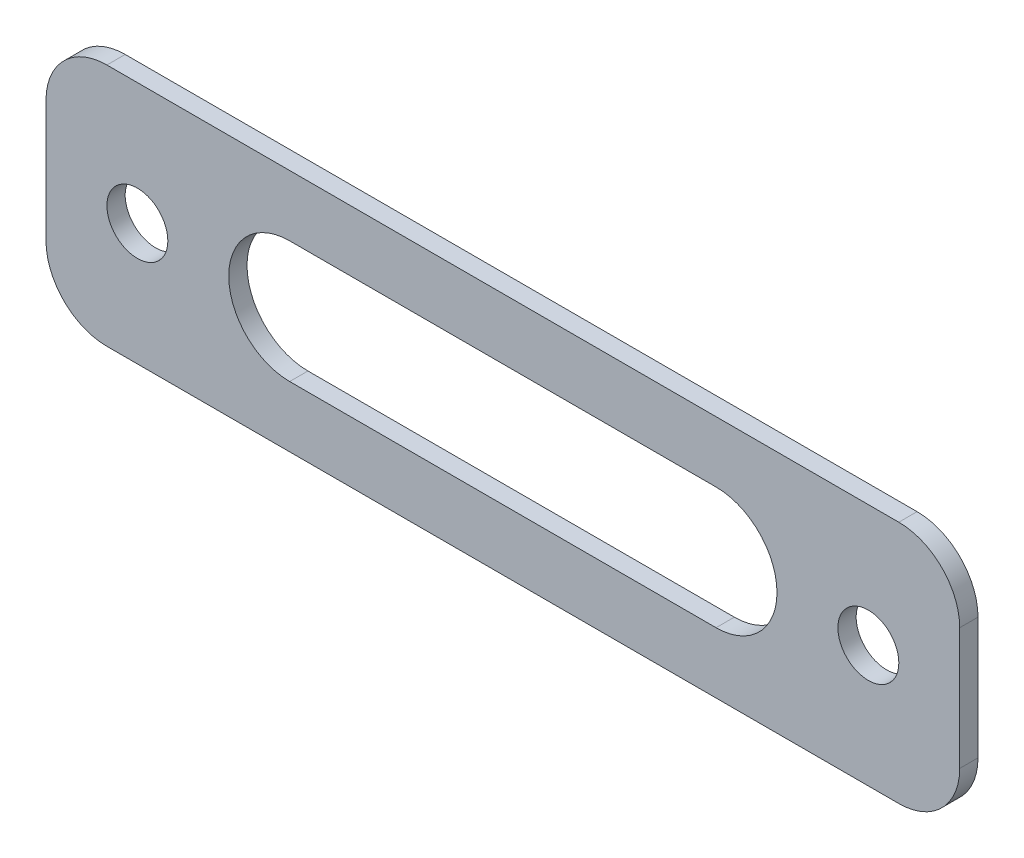
from build123d import *

# Parameters (mm, degrees)
SKETCH1_W           = 95.25
SKETCH1_H           = 25.4
SKETCH1_R           = 3.175
BOSS_EXTRUDE1_DEPTH = 1.905
CUT_EXTRUDE1_DEPTH  = 2.905
FILLET1_R           = 6.35


with BuildPart() as part:
    # Sketch1 → Boss-Extrude1 (new body)
    with BuildSketch(Plane.XY):
        Rectangle(SKETCH1_W, SKETCH1_H)
        with Locations((-38.1, 0)):
            Circle(SKETCH1_R, mode=Mode.SUBTRACT)
        with Locations((38.1, 0)):
            Circle(SKETCH1_R, mode=Mode.SUBTRACT)
    extrude(amount=BOSS_EXTRUDE1_DEPTH)

    # Sketch2 → Cut-Extrude1 (cut, through all)
    with BuildSketch(Plane.XY.offset(1.905)):
        with BuildLine():
            Line((-22.225, 6.35), (22.225, 6.35))
            ThreePointArc((22.225, 6.35), (28.575, 0), (22.225, -6.35))
            Line((22.225, -6.35), (-22.225, -6.35))
            ThreePointArc((-22.225, -6.35), (-28.575, 0), (-22.225, 6.35))
        make_face()
    extrude(amount=-CUT_EXTRUDE1_DEPTH, mode=Mode.SUBTRACT)

    # Fillet1
    fillet1_edges = [part.edges().sort_by_distance(p)[0] for p in [
        (47.625, -12.7, 0.9525),
        (-47.625, -12.7, 0.9525),
        (-47.625, 12.7, 0.9525),
        (47.625, 12.7, 0.9525),
    ]]
    fillet(fillet1_edges, radius=FILLET1_R)


solid = part.part
